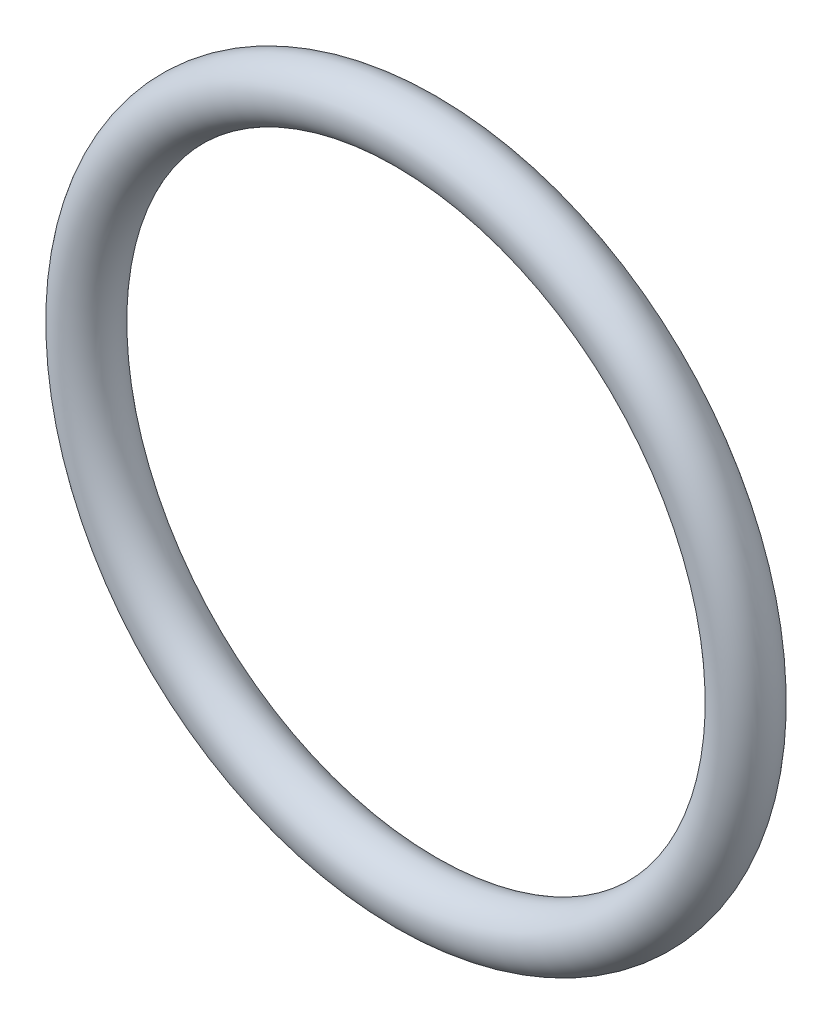
from build123d import *

# Parameters (mm, degrees)
ESQUISSE4_R = 2


with BuildPart() as part:
    # Balayage1: sweep along a path in Esquisse2
    with BuildLine(Plane.XY) as balayage1_path:
        CenterArc((0, 0), 23.00163751, 0, 360)
    # Esquisse4 → Balayage1 (sweep)
    with BuildSketch(Plane(origin=(0, 0, 0), x_dir=(0, 0, -1), z_dir=(1, 0, 0))):
        with Locations((0, 23.00163751)):
            Circle(ESQUISSE4_R)
    sweep(path=balayage1_path.line)


solid = part.part
